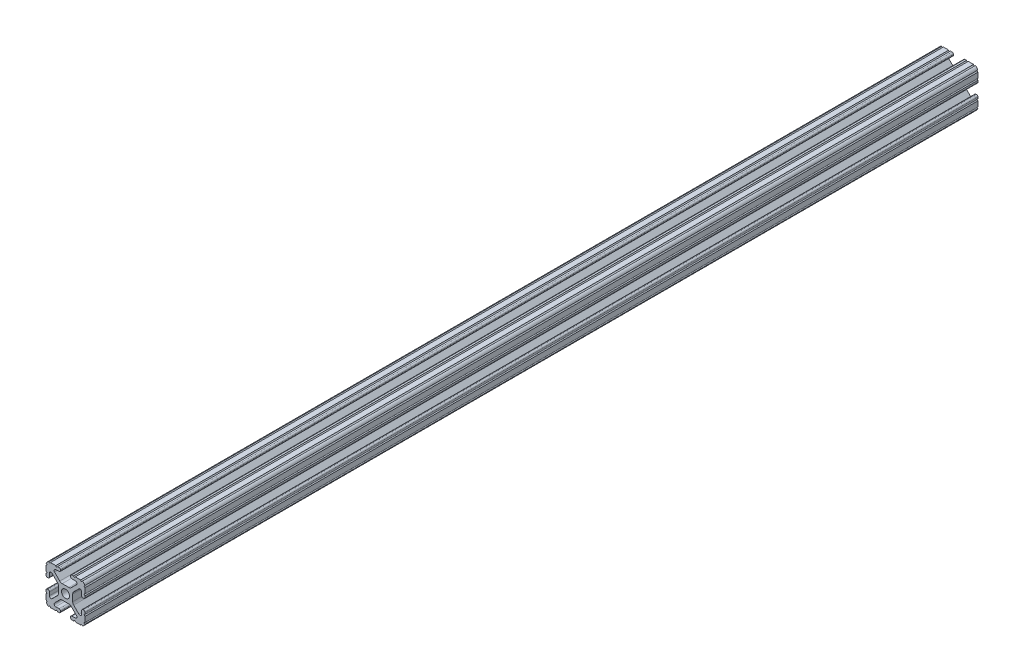
from build123d import *

# Parameters (mm, degrees)
BOSS_EXTRUDE1_DEPTH     = 304.8
SKETCH5_R               = 0.55245
CUT_EXTRUDE1_DEPTH      = 305.8
CUT_EXTRUDE1_DEPTH_BACK = 305.8
SKETCH6_W               = 28.77
SKETCH6_H               = 75.458782243
CUT_EXTRUDE2_DEPTH      = 60


with BuildPart() as part:
    # Sketch4 → Boss-Extrude1 (new body, symmetric)
    with BuildSketch(Plane.XY):
        with BuildLine():
            Line((4.190365, -12.7), (10.11729625, -12.7))
            ThreePointArc((10.11729625, -12.7), (11.943543585, -11.943543585), (12.7, -10.11729625))
            Line((12.7, -10.11729625), (12.7, -4.190365))
            ThreePointArc((12.7, -4.190365), (12.42492494, -3.52627506), (11.760835, -3.2512))
            Line((11.760835, -3.2512), (11.429365, -3.2512))
            ThreePointArc((11.429365, -3.2512), (10.76527506, -3.52627506), (10.4902, -4.190365))
            Line((10.4902, -4.190365), (10.4902, -6.348478019))
            ThreePointArc((10.4902, -6.348478019), (9.830707141, -7.335478831), (8.666460301, -7.103895736))
            Line((8.666460301, -7.103895736), (5.299899128, -3.737334563))
            ThreePointArc((5.299899128, -3.737334563), (4.817571085, -3.015479634), (4.6482, -2.16399369))
            Line((4.6482, -2.16399369), (4.6482, 0))
            Line((4.6482, 0), (2.6035, 0))
            ThreePointArc((2.6035, 0), (1.840952505, -1.840952505), (0, -2.6035))
            Line((0, -2.6035), (0, -4.6482))
            Line((0, -4.6482), (2.16399369, -4.6482))
            ThreePointArc((2.16399369, -4.6482), (3.015479634, -4.817571085), (3.737334563, -5.299899128))
            Line((3.737334563, -5.299899128), (7.103895736, -8.666460301))
            ThreePointArc((7.103895736, -8.666460301), (7.335478831, -9.830707141), (6.348478019, -10.4902))
            Line((6.348478019, -10.4902), (4.190365, -10.4902))
            ThreePointArc((4.190365, -10.4902), (3.52627506, -10.76527506), (3.2512, -11.429365))
            Line((3.2512, -11.429365), (3.2512, -11.760835))
            ThreePointArc((3.2512, -11.760835), (3.52627506, -12.42492494), (4.190365, -12.7))
        make_face()
    extrude(amount=BOSS_EXTRUDE1_DEPTH, both=True)

    # Sketch5 → Cut-Extrude1 (cut, two sides)
    with BuildSketch(Plane.XY) as cut_extrude1_sk:
        with Locations((10.356153152, -12.7)):
            Circle(SKETCH5_R)
        with Locations((5.796028019, -12.7)):
            Circle(SKETCH5_R)
        with Locations((12.7, -10.356153152)):
            Circle(SKETCH5_R)
        with Locations((12.7, -5.796028019)):
            Circle(SKETCH5_R)
    extrude(amount=CUT_EXTRUDE1_DEPTH, mode=Mode.SUBTRACT)
    extrude(cut_extrude1_sk.sketch, amount=-CUT_EXTRUDE1_DEPTH_BACK, mode=Mode.SUBTRACT)

    # Mirror1: part across plane


with BuildPart() as part_1:
    add(part.part)
    add(part.part.mirror(Plane(origin=(0, 0, 0), x_dir=(0, 0, 1), z_dir=(1, 0, 0))))

    # Mirror2: part across plane


with BuildPart() as part_2:
    add(part_1.part)
    add(part_1.part.mirror(Plane.ZX))

    # Sketch6 → Cut-Extrude2 (cut)
    with BuildSketch(Plane(origin=(12.7, 0, 0), x_dir=(0, 0, -1), z_dir=(1, 0, 0))):
        with Locations((-290.415, -8.479048352)):
            Rectangle(SKETCH6_W, SKETCH6_H)
    extrude(amount=-CUT_EXTRUDE2_DEPTH, mode=Mode.SUBTRACT)


solid = part_2.part
